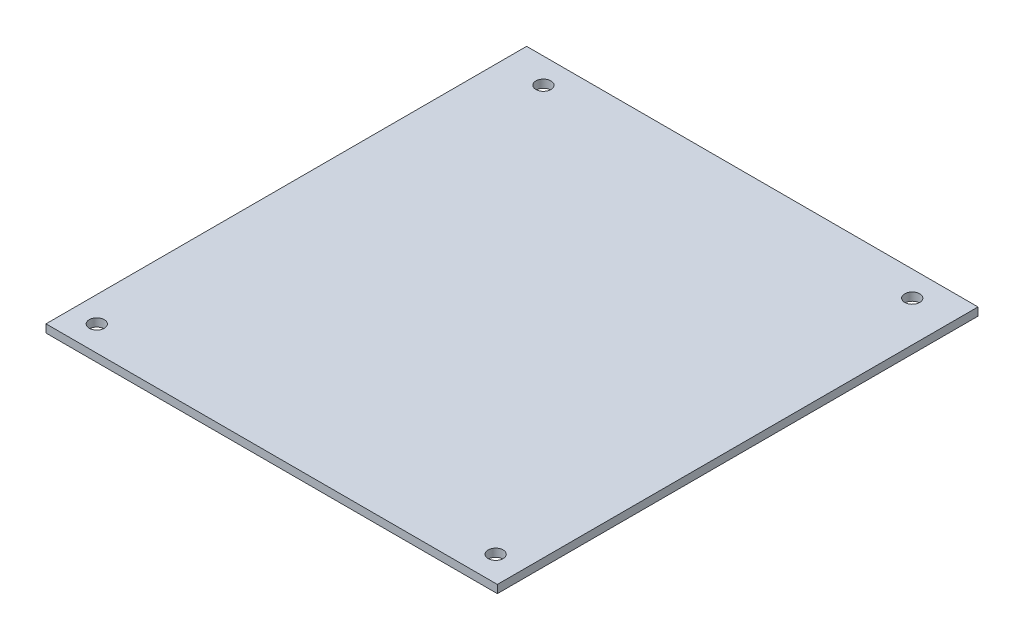
from build123d import *

# Parameters (mm, degrees)
SKETCH2_W           = 84.57
SKETCH2_H           = 90.8
BOSS_EXTRUDE1_DEPTH = 1.6
SKETCH3_R           = 1.5
CUT_EXTRUDE1_DEPTH  = 2.6
SKETCH4_W           = 90.8
SKETCH4_H           = 1.6
BOSS_EXTRUDE2_DEPTH = 2.88
SKETCH5_W           = 90.8
SKETCH5_H           = 1.6
BOSS_EXTRUDE3_DEPTH = 2.59
SKETCH6_W           = 90.04
SKETCH6_H           = 1.6
BOSS_EXTRUDE4_DEPTH = 2.54
SKETCH7_W           = 90.04
SKETCH7_H           = 1.6
BOSS_EXTRUDE5_DEPTH = 2.54


with BuildPart() as part:
    # Sketch2 → Boss-Extrude1 (new body)
    with BuildSketch(Plane(origin=(0, 0, 0), x_dir=(1, 0, 0), z_dir=(0, 1, 0))):
        with Locations((42.285, 45.4)):
            Rectangle(SKETCH2_W, SKETCH2_H)
    extrude(amount=BOSS_EXTRUDE1_DEPTH)

    # Sketch3 → Cut-Extrude1 (cut, through all)
    with BuildSketch(Plane(origin=(0, 1.6, 0), x_dir=(1, 0, 0), z_dir=(0, 1, 0))):
        with Locations((2.5, 2.5)):
            Circle(SKETCH3_R)
        with Locations((82.07, 2.5)):
            Circle(SKETCH3_R)
        with Locations((5.8, 88.3)):
            Circle(SKETCH3_R)
        with Locations((79.37, 88.3)):
            Circle(SKETCH3_R)
    extrude(amount=-CUT_EXTRUDE1_DEPTH, mode=Mode.SUBTRACT)

    # Sketch4 → Boss-Extrude2 (add)
    with BuildSketch(Plane(origin=(84.57, 0, 0), x_dir=(0, 0, -1), z_dir=(1, 0, 0))):
        with Locations((45.4, 0.8)):
            Rectangle(SKETCH4_W, SKETCH4_H)
    extrude(amount=BOSS_EXTRUDE2_DEPTH)

    # Sketch5 → Boss-Extrude3 (add)
    with BuildSketch(Plane.ZY):
        with Locations((-45.4, 0.8)):
            Rectangle(SKETCH5_W, SKETCH5_H)
    extrude(amount=BOSS_EXTRUDE3_DEPTH)

    # Sketch6 → Boss-Extrude4 (add)
    with BuildSketch(Plane(origin=(0, 0, -90.8), x_dir=(-1, 0, 0), z_dir=(0, 0, -1))):
        with Locations((-42.43, 0.8)):
            Rectangle(SKETCH6_W, SKETCH6_H)
    extrude(amount=BOSS_EXTRUDE4_DEPTH)

    # Sketch7 → Boss-Extrude5 (add)
    with BuildSketch(Plane.XY):
        with Locations((42.43, 0.8)):
            Rectangle(SKETCH7_W, SKETCH7_H)
    extrude(amount=BOSS_EXTRUDE5_DEPTH)


solid = part.part
